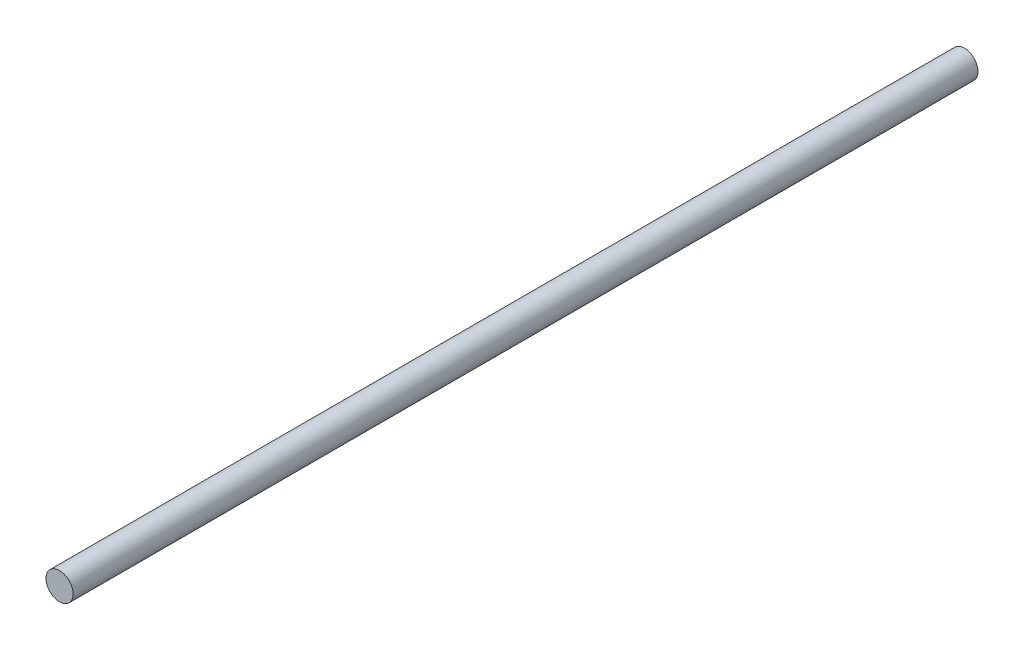
from build123d import *

# Parameters (mm, degrees)
SKETCH_1_R      = 1.5
EXTRUDE_1_DEPTH = 100


with BuildPart() as part:
    # 草图1 → 凸台-拉伸1 (new body)
    with BuildSketch(Plane.XY):
        Circle(SKETCH_1_R)
    extrude(amount=EXTRUDE_1_DEPTH)


solid = part.part
